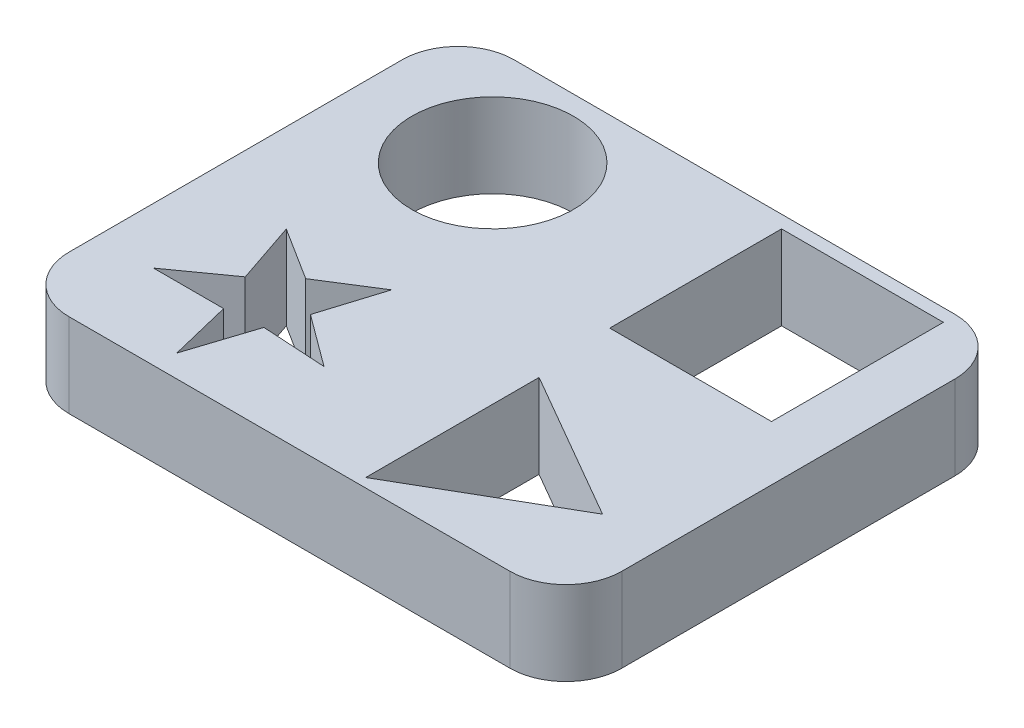
from build123d import *

# Parameters (mm, degrees)
SKETCH1_R           = 7.338508892
SKETCH1_W           = 14.683745891
SKETCH1_H           = 15.594449323
BOSS_EXTRUDE6_DEPTH = 7.62


with BuildPart() as part:
    # Sketch1 → Boss-Extrude6 (new body)
    with BuildSketch(Plane(origin=(0, 0, 0), x_dir=(1, 0, 0), z_dir=(0, 1, 0))):
        with BuildLine():
            Line((-33.85382456, 51.361208868), (6.15117544, 51.361208868))
            ThreePointArc((6.15117544, 51.361208868), (9.743277889, 49.873311317), (11.23117544, 46.281208868))
            Line((11.23117544, 46.281208868), (11.23117544, 16.055208868))
            ThreePointArc((11.23117544, 16.055208868), (9.743277889, 12.46310642), (6.15117544, 10.975208868))
            Line((6.15117544, 10.975208868), (-33.85382456, 10.975208868))
            ThreePointArc((-33.85382456, 10.975208868), (-37.445927008, 12.46310642), (-38.93382456, 16.055208868))
            Line((-38.93382456, 16.055208868), (-38.93382456, 46.281208868))
            ThreePointArc((-38.93382456, 46.281208868), (-37.445927008, 49.873311317), (-33.85382456, 51.361208868))
        make_face()
        with Locations((-26.728784531, 42.288093859)):
            Circle(SKETCH1_R, mode=Mode.SUBTRACT)
        Polygon((-26.110126673, 13.007611736), (-27.479198511, 18.629319113), (-33.847743068, 18.629319113), (-28.993277919, 22.103725346), (-30.892236597, 27.725432723), (-26.110126673, 24.705324634), (-21.328016749, 27.725432723), (-23.076426813, 22.103725346), (-18.372510278, 18.629319113), (-24.17123819, 18.974896902), align=None, mode=Mode.SUBTRACT)
        with Locations((-1.086674016, 42.41081801)):
            Rectangle(SKETCH1_W, SKETCH1_H, mode=Mode.SUBTRACT)
        Polygon((5.867569864, 19.665294437), (-7.758291576, 27.532189206), (-7.758291576, 11.798399667), align=None, mode=Mode.SUBTRACT)
    extrude(amount=BOSS_EXTRUDE6_DEPTH)


solid = part.part
